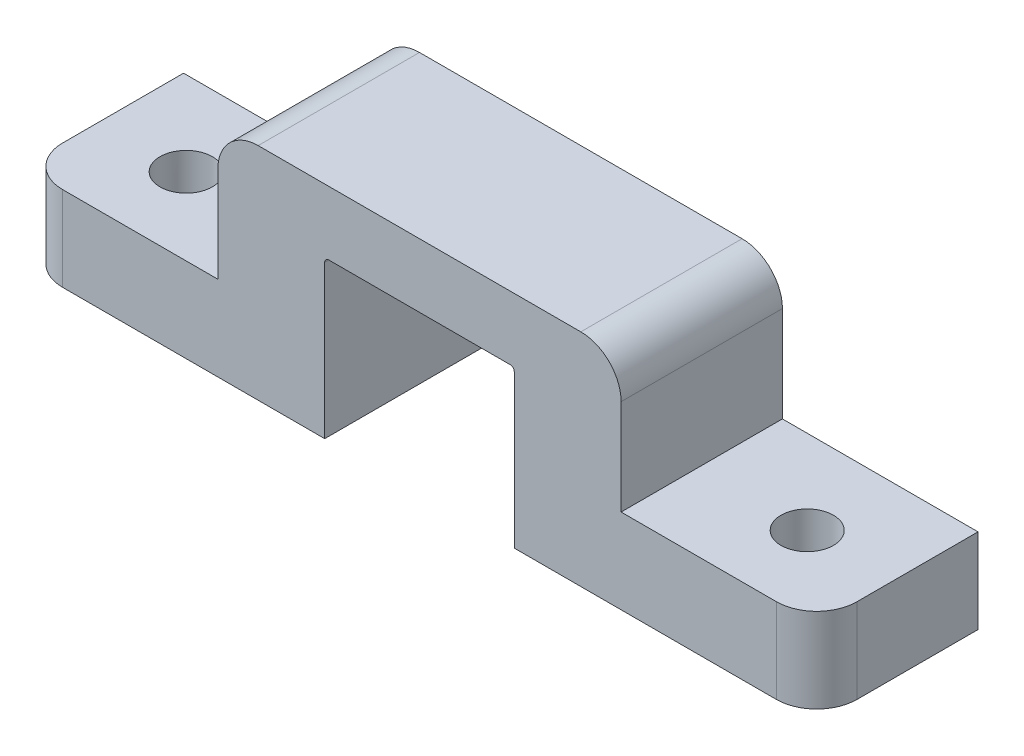
from build123d import *

# Parameters (mm, degrees)
BOSS_EXTRUDE1_DEPTH = 10.16
FILLET1_R           = 2.54
SKETCH3_R           = 1.651
CUT_EXTRUDE1_DEPTH  = 10.16
FILLET2_R           = 0.254


with BuildPart() as part:
    # Sketch2 → Boss-Extrude1 (new body)
    with BuildSketch(Plane.XY):
        Polygon((12.7, 13.894017094), (-12.7, 13.894017094), (-12.7, 5.334), (-25.019, 5.334), (-25.019, 0), (-5.969, 0), (-5.969, 9.877777778), (5.969, 9.877777778), (5.969, 0), (25.019, 0), (25.019, 5.334), (12.7, 5.334), align=None)
    extrude(amount=BOSS_EXTRUDE1_DEPTH)

    # Fillet1
    fillet1_edges = [part.edges().sort_by_distance(p)[0] for p in [
        (-12.7, 13.894017094, 5.08),
        (12.7, 13.894017094, 5.08),
        (-25.019, 2.667, 10.16),
        (25.019, 2.667, 10.16),
    ]]
    fillet(fillet1_edges, radius=FILLET1_R)

    # Sketch3 → Cut-Extrude1 (cut)
    with BuildSketch(Plane(origin=(0, 0, 0), x_dir=(1, 0, 0), z_dir=(0, 1, 0))):
        with Locations((-19.558, -5.296219795)):
            Circle(SKETCH3_R)
        with Locations((19.558, -5.296219795)):
            Circle(SKETCH3_R)
    extrude(amount=CUT_EXTRUDE1_DEPTH, mode=Mode.SUBTRACT)

    # Fillet2
    fillet2_edges = [part.edges().sort_by_distance(p)[0] for p in [
        (5.969, 9.877777778, 5.08),
        (-5.969, 9.877777778, 5.08),
    ]]
    fillet(fillet2_edges, radius=FILLET2_R)


solid = part.part
